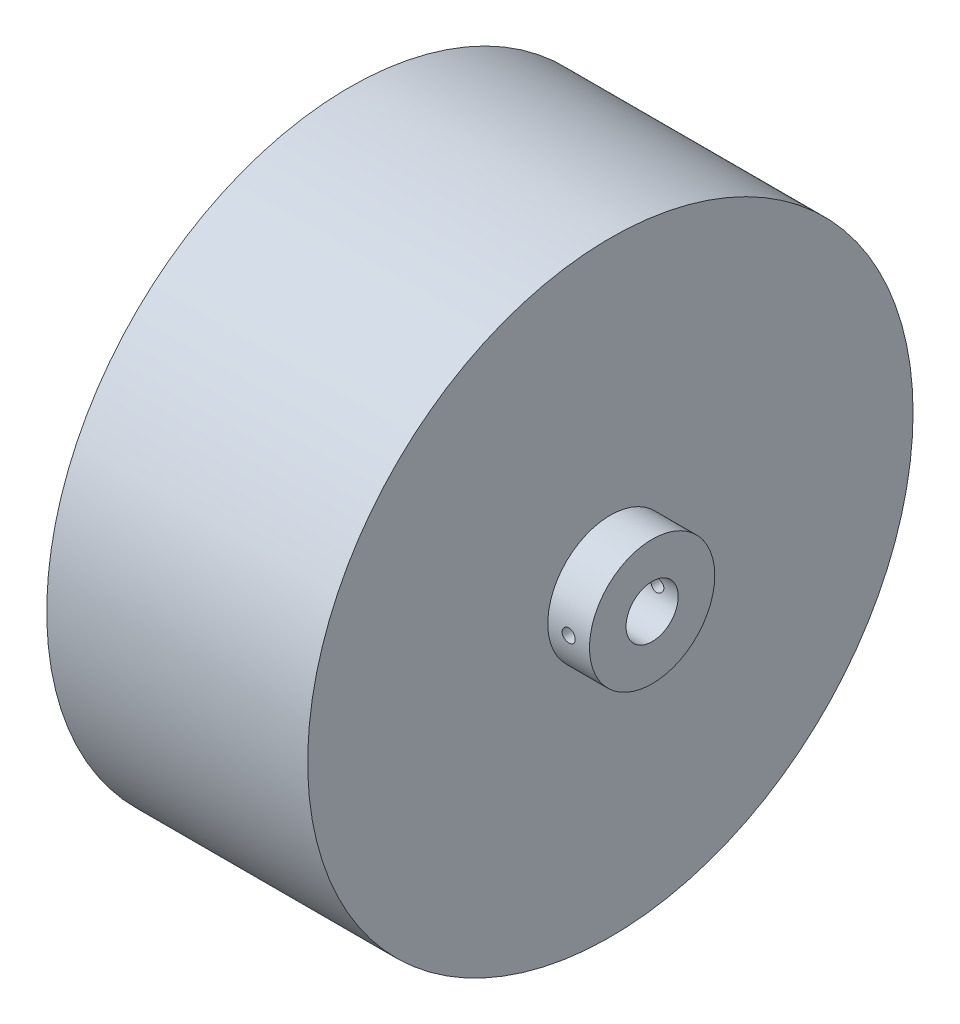
from build123d import *

# Parameters (mm, degrees)
SKETCH1_R               = 36.83
BOSS_EXTRUDE1_DEPTH     = 31.75
SKETCH3_R               = 7.62
BOSS_EXTRUDE2_DEPTH     = 5.08
BOSS_EXTRUDE3_START     = -31.75
SKETCH3_2_R             = 7.62
BOSS_EXTRUDE3_DEPTH     = 5.08
SKETCH2_R               = 3.175
CUT_EXTRUDE1_DEPTH      = 6.08
CUT_EXTRUDE1_DEPTH_BACK = 37.83
SKETCH4_R               = 0.79375
CUT_EXTRUDE2_DEPTH      = 37.83
CUT_EXTRUDE2_DEPTH_BACK = 37.83
SKETCH5_W               = 11.37457975
SKETCH5_H               = 27.007523476
CUT_EXTRUDE3_DEPTH      = 37.83
CUT_EXTRUDE3_DEPTH_BACK = 37.83


with BuildPart() as part:
    # Sketch1 → Boss-Extrude1 (new body)
    with BuildSketch(Plane(origin=(0, 0, 0), x_dir=(0, 0, -1), z_dir=(1, 0, 0))):
        Circle(SKETCH1_R)
    extrude(amount=BOSS_EXTRUDE1_DEPTH)

    # Sketch3 → Boss-Extrude2 (add)
    with BuildSketch(Plane(origin=(31.75, 0, 0), x_dir=(0, 0, -1), z_dir=(1, 0, 0))):
        Circle(SKETCH3_R)
    extrude(amount=BOSS_EXTRUDE2_DEPTH)

    # Sketch3_2 → Boss-Extrude3 (add)
    with BuildSketch(Plane(origin=(31.75, 0, 0), x_dir=(0, 0, -1), z_dir=(1, 0, 0)).offset(BOSS_EXTRUDE3_START)):
        Circle(SKETCH3_2_R)
    extrude(amount=-BOSS_EXTRUDE3_DEPTH)

    # Sketch2 → Cut-Extrude1 (cut, two sides)
    with BuildSketch(Plane(origin=(31.75, 0, 0), x_dir=(0, 0, -1), z_dir=(1, 0, 0))) as cut_extrude1_sk:
        Circle(SKETCH2_R)
    extrude(amount=CUT_EXTRUDE1_DEPTH, mode=Mode.SUBTRACT)
    extrude(cut_extrude1_sk.sketch, amount=-CUT_EXTRUDE1_DEPTH_BACK, mode=Mode.SUBTRACT)

    # Sketch4 → Cut-Extrude2 (cut, two sides)
    with BuildSketch(Plane.XY) as cut_extrude2_sk:
        with Locations((34.29, 0)):
            Circle(SKETCH4_R)
        with Locations((-2.54, 0)):
            Circle(SKETCH4_R)
    extrude(amount=CUT_EXTRUDE2_DEPTH, mode=Mode.SUBTRACT)
    extrude(cut_extrude2_sk.sketch, amount=-CUT_EXTRUDE2_DEPTH_BACK, mode=Mode.SUBTRACT)

    # Sketch5 → Cut-Extrude3 (cut, two sides)
    with BuildSketch(Plane(origin=(0, 0, 0), x_dir=(1, 0, 0), z_dir=(0, 1, 0))) as cut_extrude3_sk:
        with Locations((-5.687289875, -0.244411977)):
            Rectangle(SKETCH5_W, SKETCH5_H)
    extrude(amount=CUT_EXTRUDE3_DEPTH, mode=Mode.SUBTRACT)
    extrude(cut_extrude3_sk.sketch, amount=-CUT_EXTRUDE3_DEPTH_BACK, mode=Mode.SUBTRACT)


solid = part.part
